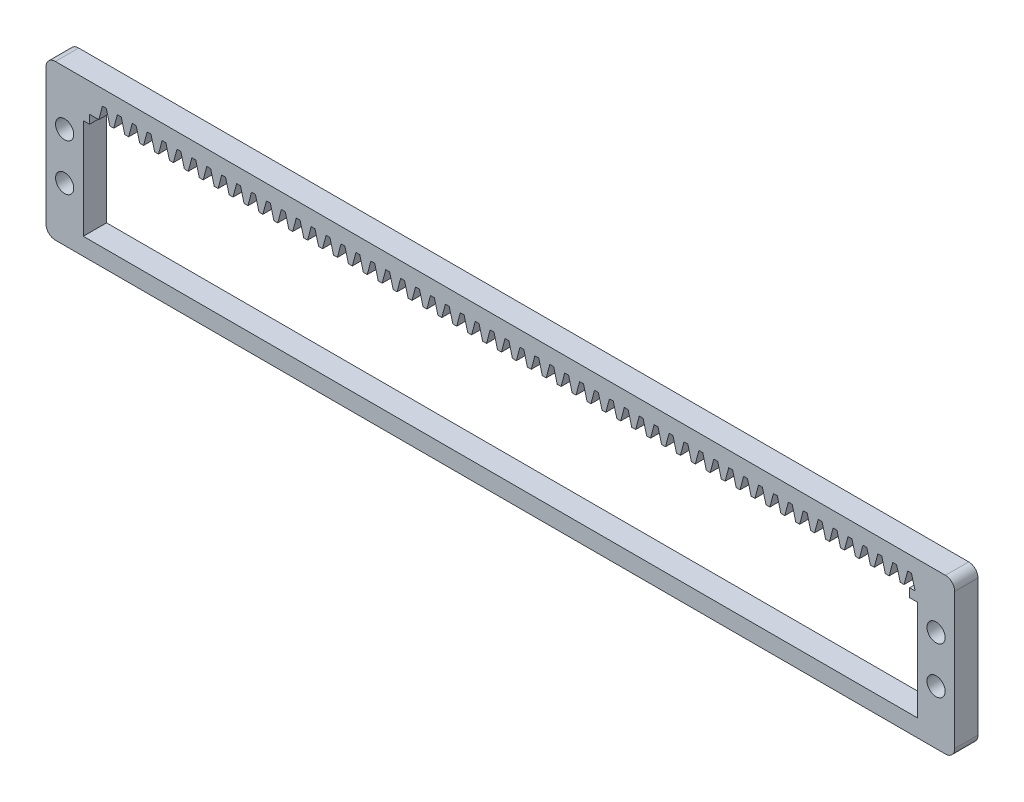
from build123d import *

# Parameters (mm, degrees)
BOSS_EXTRUDE1_DEPTH = 5
SKETCH2_W           = 179
SKETCH2_H           = 21.5
CUT_EXTRUDE1_DEPTH  = 6
SKETCH3_W           = 175.97
SKETCH3_H           = 1.85
CUT_EXTRUDE2_DEPTH  = 6
CUT_EXTRUDE4_DEPTH  = 6
LPATTERN1_COUNT     = 55
LPATTERN1_PITCH     = 3.2
SKETCH5_R           = 1.95
CUT_EXTRUDE5_DEPTH  = 10


with BuildPart() as part:
    # Sketch1 → Boss-Extrude1 (new body)
    with BuildSketch(Plane.XY):
        with BuildLine():
            Line((2, 0), (193, 0))
            ThreePointArc((193, 0), (194.414213562, -0.585786438), (195, -2))
            Line((195, -2), (195, -31.22))
            ThreePointArc((195, -31.22), (194.414213562, -32.634213562), (193, -33.22))
            Line((193, -33.22), (2, -33.22))
            ThreePointArc((2, -33.22), (0.585786438, -32.634213562), (0, -31.22))
            Line((0, -31.22), (0, -2))
            ThreePointArc((0, -2), (0.585786438, -0.585786438), (2, 0))
        make_face()
    extrude(amount=BOSS_EXTRUDE1_DEPTH)

    # Sketch2 → Cut-Extrude1 (cut, through all)
    with BuildSketch(Plane.XY.offset(5)):
        with Locations((97.5, -18.75)):
            Rectangle(SKETCH2_W, SKETCH2_H)
    extrude(amount=-CUT_EXTRUDE1_DEPTH, mode=Mode.SUBTRACT)

    # Sketch3 → Cut-Extrude2 (cut, through all)
    with BuildSketch(Plane.XY.offset(5)):
        with Locations((97.335, -7.075)):
            Rectangle(SKETCH3_W, SKETCH3_H)
    extrude(amount=-CUT_EXTRUDE2_DEPTH, mode=Mode.SUBTRACT)

    # Sketch4 → Cut-Extrude4 (cut, through all)
    with BuildSketch(Plane.XY.offset(5)):
        Polygon((185.735, -3.249176841), (186.5, -6.15), (184.14, -6.15), (184.905, -3.249176841), align=None)
    cut_extrude4 = extrude(amount=-CUT_EXTRUDE4_DEPTH, mode=Mode.SUBTRACT)

    # LPattern1: Cut-Extrude4 ×55
    with Locations(*[(-i * LPATTERN1_PITCH, 0, 0) for i in range(1, LPATTERN1_COUNT)]):
        add(cut_extrude4, mode=Mode.SUBTRACT)

    # Sketch5 → Cut-Extrude5 (cut)
    with BuildSketch(Plane.XY.offset(5)):
        with Locations((4, -11.61)):
            Circle(SKETCH5_R)
        with Locations((4, -21.61)):
            Circle(SKETCH5_R)
        with Locations((191, -11.61)):
            Circle(SKETCH5_R)
        with Locations((191, -21.61)):
            Circle(SKETCH5_R)
    extrude(amount=-CUT_EXTRUDE5_DEPTH, mode=Mode.SUBTRACT)


solid = part.part
